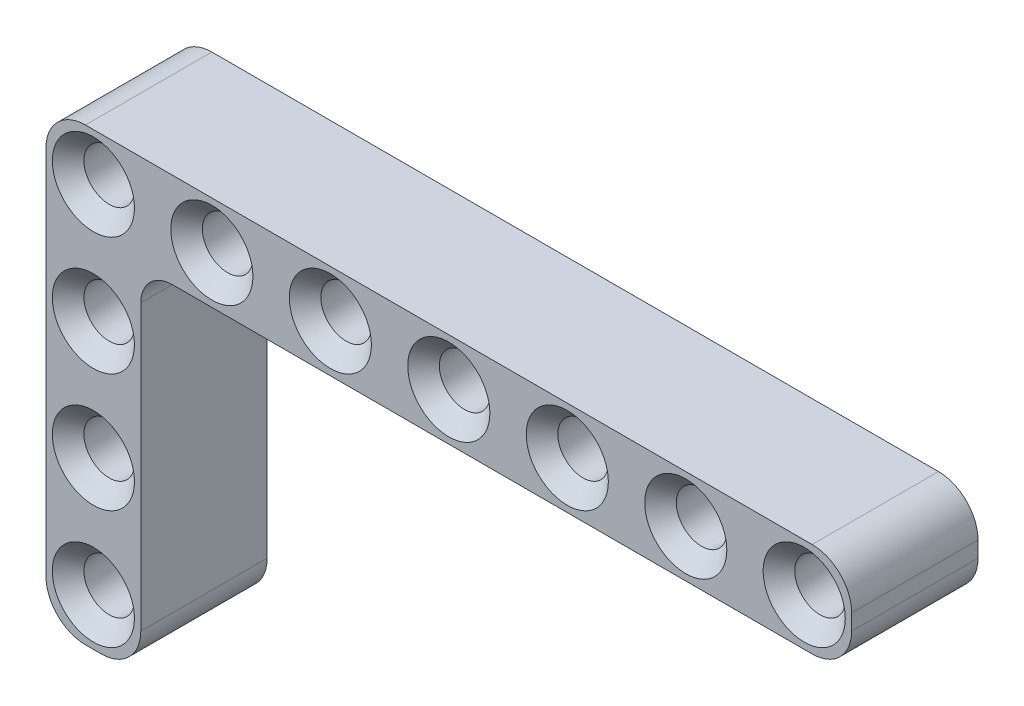
from build123d import *

# Parameters (mm, degrees)
SKETCH1_R           = 1.6
BOSS_EXTRUDE1_DEPTH = 8
CHAMFER1_SIZE       = 1
SKETCH2_R           = 1.6
BOSS_EXTRUDE3_DEPTH = 8
FILLET1_R           = 2
CHAMFER3_SIZE       = 1
CHAMFER5_SIZE       = 1


with BuildPart() as part:
    # Sketch1 → Boss-Extrude1 (new body)
    with BuildSketch(Plane.XY):
        with BuildLine():
            Line((-0.5, 3), (45.5, 3))
            ThreePointArc((45.5, 3), (47.267766953, 2.267766953), (48, 0.5))
            Line((48, 0.5), (48, -0.5))
            ThreePointArc((48, -0.5), (47.267766953, -2.267766953), (45.5, -3))
            Line((45.5, -3), (-0.5, -3))
            ThreePointArc((-0.5, -3), (-2.267766953, -2.267766953), (-3, -0.5))
            Line((-3, -0.5), (-3, 0.5))
            ThreePointArc((-3, 0.5), (-2.267766953, 2.267766953), (-0.5, 3))
        make_face()
        Circle(SKETCH1_R, mode=Mode.SUBTRACT)
        with Locations((7.5, 0)):
            Circle(SKETCH1_R, mode=Mode.SUBTRACT)
        with Locations((15, 0)):
            Circle(SKETCH1_R, mode=Mode.SUBTRACT)
        with Locations((22.5, 0)):
            Circle(SKETCH1_R, mode=Mode.SUBTRACT)
        with Locations((30, 0)):
            Circle(SKETCH1_R, mode=Mode.SUBTRACT)
        with Locations((37.5, 0)):
            Circle(SKETCH1_R, mode=Mode.SUBTRACT)
        with Locations((45, 0)):
            Circle(SKETCH1_R, mode=Mode.SUBTRACT)
    extrude(amount=BOSS_EXTRUDE1_DEPTH)

    # Chamfer1
    chamfer1_edges = [part.edges().sort_by_distance(p)[0] for p in [
        (-1.6, 0, 0),
        (-1.6, 0, 8),
        (5.9, 0, 0),
        (5.9, 0, 8),
        (13.4, 0, 0),
        (13.4, 0, 8),
        (20.9, 0, 0),
        (20.9, 0, 8),
        (28.4, 0, 0),
        (28.4, 0, 8),
    ]]
    chamfer(chamfer1_edges, length=CHAMFER1_SIZE)

    # Sketch2 → Boss-Extrude3 (add)
    with BuildSketch(Plane.XY.offset(8)):
        with BuildLine():
            ThreePointArc((-0.5, -3), (-2.267766953, -2.267766953), (-3, -0.5))
            Line((-3, -0.5), (-3, -23))
            ThreePointArc((-3, -23), (-2.267766953, -24.767766953), (-0.5, -25.5))
            Line((-0.5, -25.5), (0.5, -25.5))
            ThreePointArc((0.5, -25.5), (2.267766953, -24.767766953), (3, -23))
            Line((3, -23), (3, -3))
            Line((3, -3), (-0.5, -3))
        make_face()
        with Locations((0, -22.5)):
            Circle(SKETCH2_R, mode=Mode.SUBTRACT)
        with Locations((0, -15)):
            Circle(SKETCH2_R, mode=Mode.SUBTRACT)
        with Locations((0, -7.5)):
            Circle(SKETCH2_R, mode=Mode.SUBTRACT)
    extrude(amount=-BOSS_EXTRUDE3_DEPTH)

    # Fillet1
    fillet1_edges = [part.edges().sort_by_distance(p)[0] for p in [
        (3, -3, 4),
    ]]
    fillet(fillet1_edges, radius=FILLET1_R)

    # Chamfer3
    chamfer3_edges = [part.edges().sort_by_distance(p)[0] for p in [
        (35.9, 0, 0),
        (35.9, 0, 8),
        (43.4, 0, 0),
        (43.4, 0, 8),
    ]]
    chamfer(chamfer3_edges, length=CHAMFER3_SIZE)

    # Chamfer5
    chamfer5_edges = [part.edges().sort_by_distance(p)[0] for p in [
        (-1.6, -7.5, 8),
        (-1.6, -15, 8),
        (-1.6, -22.5, 8),
        (-1.6, -22.5, 0),
        (-1.6, -15, 0),
        (-1.6, -7.5, 0),
    ]]
    chamfer(chamfer5_edges, length=CHAMFER5_SIZE)


solid = part.part
